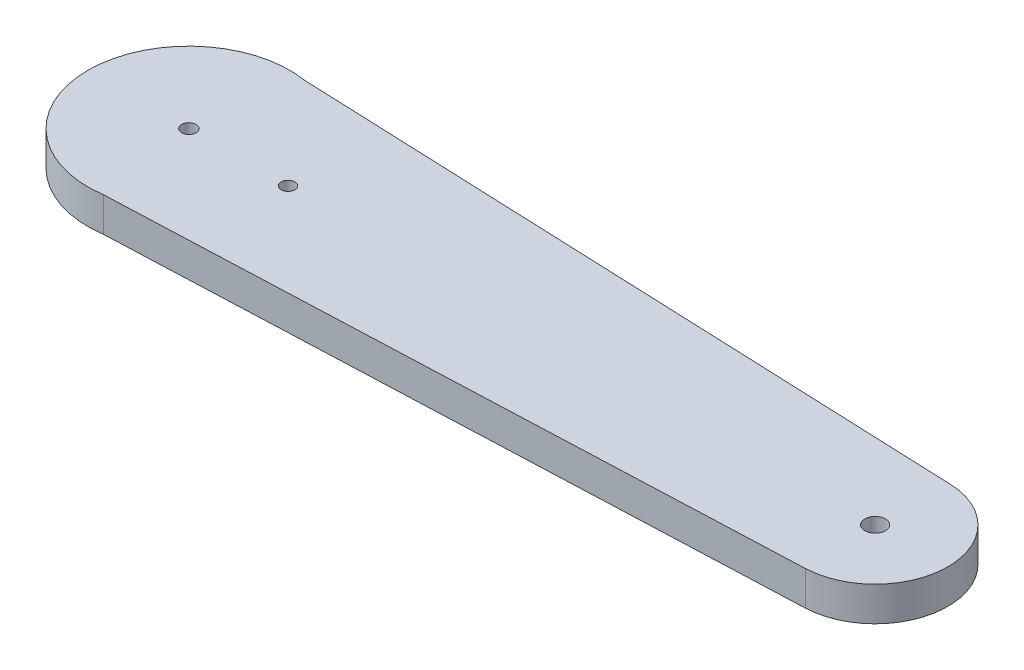
from build123d import *

# Parameters (mm, degrees)
SKETCH1_R               = 1.05
SKETCH1_R_2             = 1.5
BOSS_EXTRUDE1_DEPTH     = 5
SKETCH2_R               = 1
CUT_EXTRUDE1_DEPTH      = 1
CUT_EXTRUDE1_DEPTH_BACK = 6


with BuildPart() as part:
    # Sketch1 → Boss-Extrude1 (new body)
    with BuildSketch(Plane(origin=(0, 0, 0), x_dir=(1, 0, 0), z_dir=(0, 1, 0))):
        with BuildLine():
            Line((-50.348842759, 14.527458054), (47.631245247, 10.594116014))
            ThreePointArc((47.631245247, 10.594116014), (57.878041754, 0.037488485), (47.706171294, -10.591353165))
            Line((47.706171294, -10.591353165), (-50.583585242, -14.563860903))
            ThreePointArc((-50.583585242, -14.563860903), (-67.441412758, 0.118774156), (-50.348842759, 14.527458054))
        make_face()
        with Locations((-52.721891954, 0)):
            Circle(SKETCH1_R, mode=Mode.SUBTRACT)
        with Locations((47.278108046, 0)):
            Circle(SKETCH1_R_2, mode=Mode.SUBTRACT)
    extrude(amount=BOSS_EXTRUDE1_DEPTH)

    # Sketch2 → Cut-Extrude1 (cut, two sides)
    with BuildSketch(Plane(origin=(0, 5, 0), x_dir=(1, 0, 0), z_dir=(0, 1, 0))) as cut_extrude1_sk:
        with Locations((-38.271891954, 0)):
            Circle(SKETCH2_R)
    extrude(amount=CUT_EXTRUDE1_DEPTH, mode=Mode.SUBTRACT)
    extrude(cut_extrude1_sk.sketch, amount=-CUT_EXTRUDE1_DEPTH_BACK, mode=Mode.SUBTRACT)


solid = part.part
